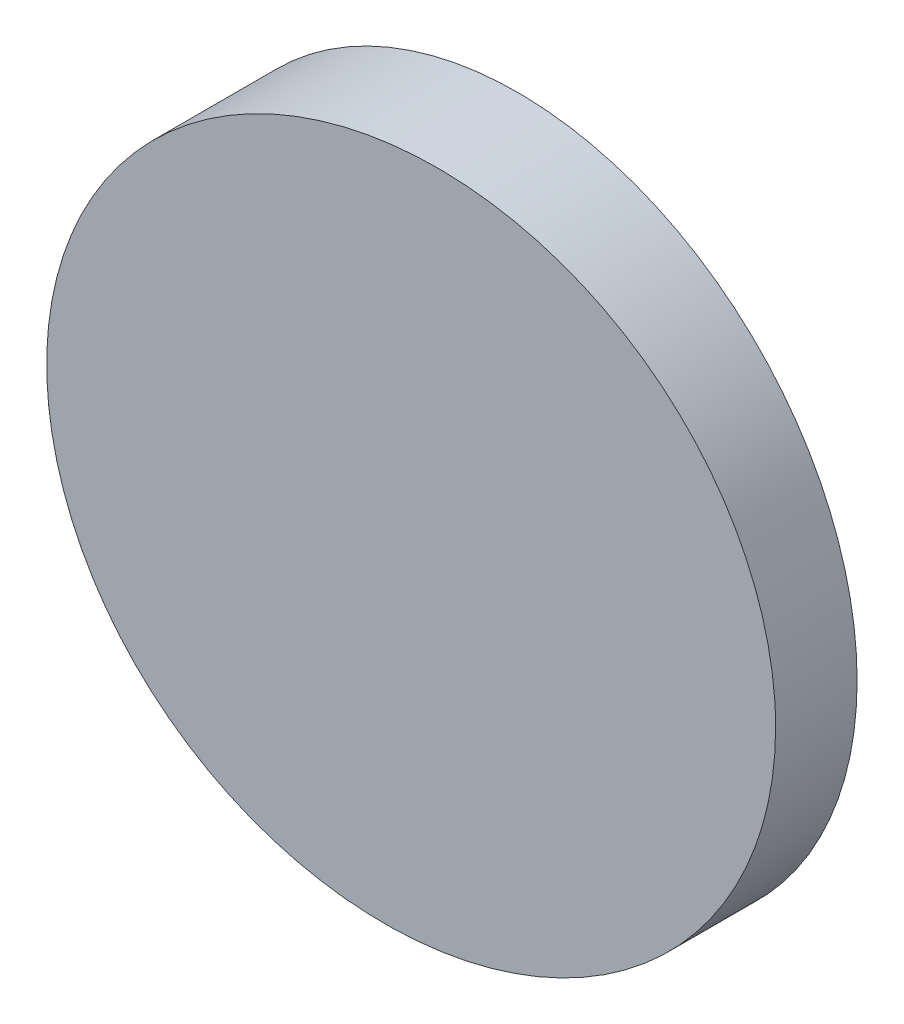
from build123d import *

# Parameters (mm, degrees)
SKETCH_1_R          = 12.5
EXTRUDE_1_DEPTH     = 10
CUT_EXTRUDE_1_DEPTH = 25


with BuildPart() as part:
    # 草图1 → 凸台-拉伸1 (new body)
    with BuildSketch(Plane.XY):
        Circle(SKETCH_1_R)
    extrude(amount=EXTRUDE_1_DEPTH)

    # 草图2 → 切除-拉伸1 (cut, symmetric)
    with BuildSketch(Plane(origin=(0, 0, 0), x_dir=(1, 0, 0), z_dir=(0, 1, 0))):
        Polygon((12.5, -3), (-16.564366405, -5.127723704), (-16.564366405, -16.065556693), (17.844464677, -16.065556693), (17.844464677, -3), align=None)
    extrude(amount=CUT_EXTRUDE_1_DEPTH, both=True, mode=Mode.SUBTRACT)


solid = part.part
